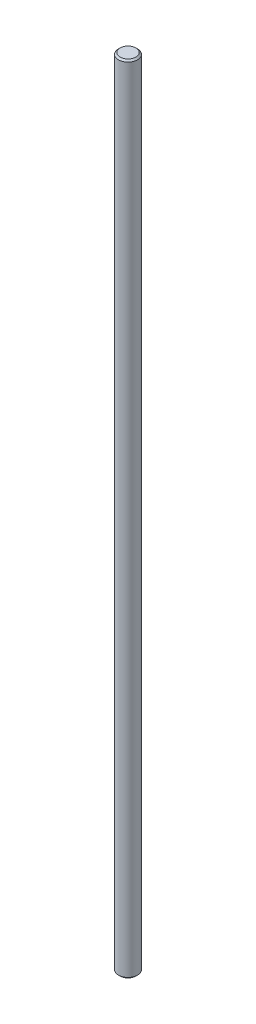
from build123d import *

# Parameters (mm, degrees)
SKETCH1_R           = 3
BOSS_EXTRUDE1_DEPTH = 250
CHAMFER1_SIZE       = 0.5


with BuildPart() as part:
    # Sketch1 → Boss-Extrude1 (new body)
    with BuildSketch(Plane(origin=(0, 0, 0), x_dir=(1, 0, 0), z_dir=(0, 1, 0))):
        Circle(SKETCH1_R)
    extrude(amount=BOSS_EXTRUDE1_DEPTH)

    # Chamfer1
    chamfer1_edges = [part.edges().sort_by_distance(p)[0] for p in [
        (-3, 0, 0),
        (-3, 250, 0),
    ]]
    chamfer(chamfer1_edges, length=CHAMFER1_SIZE)


solid = part.part
